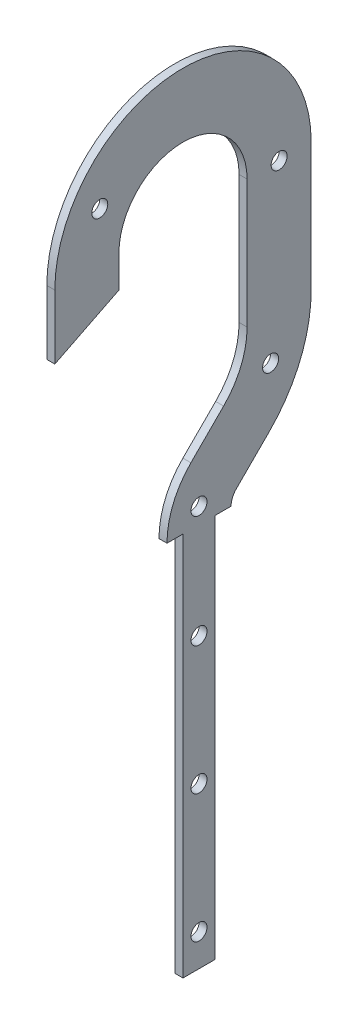
from build123d import *

# Parameters (mm, degrees)
BOSS_EXTRUDE1_DEPTH = 3.175
SKETCH2_R           = 3.175
CUT_EXTRUDE1_DEPTH  = 4.175


with BuildPart() as part:
    # Sketch1 → Boss-Extrude1 (new body)
    with BuildSketch(Plane(origin=(0, 0, 0), x_dir=(0, 0, -1), z_dir=(1, 0, 0))):
        with BuildLine():
            Line((-50.8, 0), (-50.8, -25.4))
            Line((-50.8, -25.4), (-25.4, -12.7))
            Line((-25.4, -12.7), (-25.4, 0))
            ThreePointArc((-25.4, 0), (0, 25.4), (25.4, 0))
            Line((25.4, 0), (25.4, -50.8))
            ThreePointArc((25.4, -50.8), (22.983175157, -62.950198978), (16.100640303, -73.250640303))
            Line((16.100640303, -73.250640303), (3.130634922, -86.220645683))
            ThreePointArc((3.130634922, -86.220645683), (-3.886063261, -96.721876619), (-6.35, -109.108923092))
            Line((-6.35, -109.108923092), (0, -109.108923092))
            Line((0, -109.108923092), (0, -261.508923092))
            Line((0, -261.508923092), (12.7, -261.508923092))
            Line((12.7, -261.508923092), (12.7, -109.108923092))
            Line((12.7, -109.108923092), (19.05, -109.108923092))
            ThreePointArc((19.05, -109.108923092), (19.580476865, -106.442035801), (21.091147164, -104.181157925))
            Line((21.091147164, -104.181157925), (34.061152545, -91.211152545))
            ThreePointArc((34.061152545, -91.211152545), (46.449715283, -72.67035816), (50.8, -50.8))
            Line((50.8, -50.8), (50.8, 0))
            ThreePointArc((50.8, 0), (0, 50.8), (-50.8, 0))
        make_face()
    extrude(amount=BOSS_EXTRUDE1_DEPTH)

    # Sketch2 → Cut-Extrude1 (cut, through all)
    with BuildSketch(Plane(origin=(3.175, 0, 0), x_dir=(0, 0, -1), z_dir=(1, 0, 0))):
        with Locations((38.1, 0)):
            Circle(SKETCH2_R)
        with Locations((-32.995567884, 19.05)):
            Circle(SKETCH2_R)
        with Locations((34.71644522, -67.810278569)):
            Circle(SKETCH2_R)
        with Locations((6.35, -102.758923092)):
            Circle(SKETCH2_R)
        with Locations((6.35, -248.808923092)):
            Circle(SKETCH2_R)
        with Locations((6.35, -198.008923092)):
            Circle(SKETCH2_R)
        with Locations((6.35, -147.208923092)):
            Circle(SKETCH2_R)
    extrude(amount=-CUT_EXTRUDE1_DEPTH, mode=Mode.SUBTRACT)


solid = part.part
